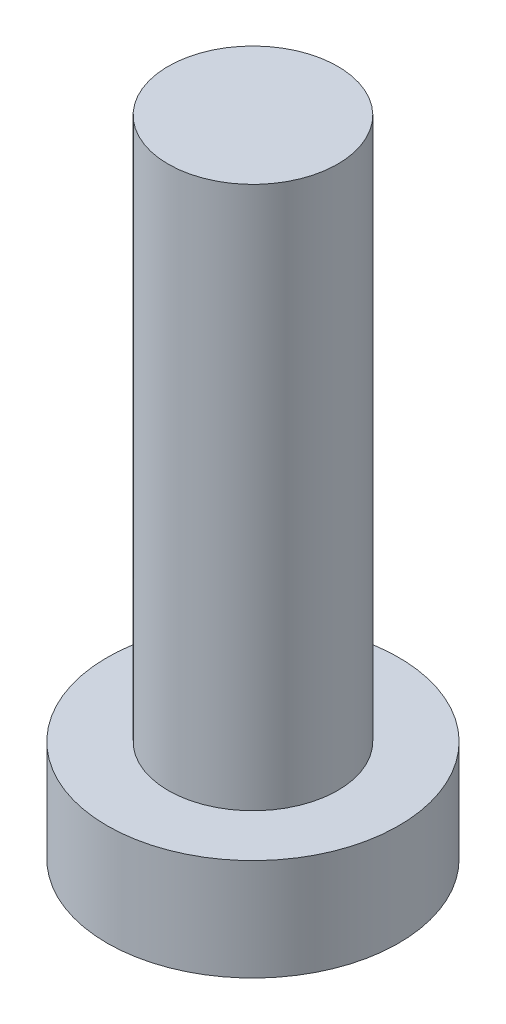
from build123d import *

# Parameters (mm, degrees)
SKETCH_1_R          = 4.3
EXTRUDE_1_DEPTH     = 3
SKETCH_2_R          = 2.5
EXTRUDE_2_DEPTH     = 16
CUT_EXTRUDE_1_DEPTH = 1.5


with BuildPart() as part:
    # 草图1 → 凸台-拉伸1 (new body)
    with BuildSketch(Plane(origin=(0, 0, 0), x_dir=(1, 0, 0), z_dir=(0, 1, 0))):
        Circle(SKETCH_1_R)
    extrude(amount=EXTRUDE_1_DEPTH)

    # 草图2 → 凸台-拉伸2 (add)
    with BuildSketch(Plane(origin=(0, 3, 0), x_dir=(1, 0, 0), z_dir=(0, 1, 0))):
        Circle(SKETCH_2_R)
    extrude(amount=EXTRUDE_2_DEPTH)

    # 草图3 → 切除-拉伸1 (cut)
    with BuildSketch(Plane.XZ):
        with BuildLine():
            Line((-0.6, 1.1), (-0.6, 2.4))
            Line((-0.6, 2.4), (0.6, 2.4))
            Line((0.6, 2.4), (0.6, 1.1))
            ThreePointArc((0.6, 1.1), (0.746446609, 0.746446609), (1.1, 0.6))
            Line((1.1, 0.6), (2.4, 0.6))
            Line((2.4, 0.6), (2.4, -0.6))
            Line((2.4, -0.6), (1.1, -0.6))
            ThreePointArc((1.1, -0.6), (0.746446609, -0.746446609), (0.6, -1.1))
            Line((0.6, -1.1), (0.6, -2.4))
            Line((0.6, -2.4), (-0.6, -2.4))
            Line((-0.6, -2.4), (-0.6, -1.1))
            ThreePointArc((-0.6, -1.1), (-0.746446609, -0.746446609), (-1.1, -0.6))
            Line((-1.1, -0.6), (-2.4, -0.6))
            Line((-2.4, -0.6), (-2.4, 0.6))
            Line((-2.4, 0.6), (-1.1, 0.6))
            ThreePointArc((-1.1, 0.6), (-0.746446609, 0.746446609), (-0.6, 1.1))
        make_face()
    extrude(amount=-CUT_EXTRUDE_1_DEPTH, mode=Mode.SUBTRACT)


solid = part.part
